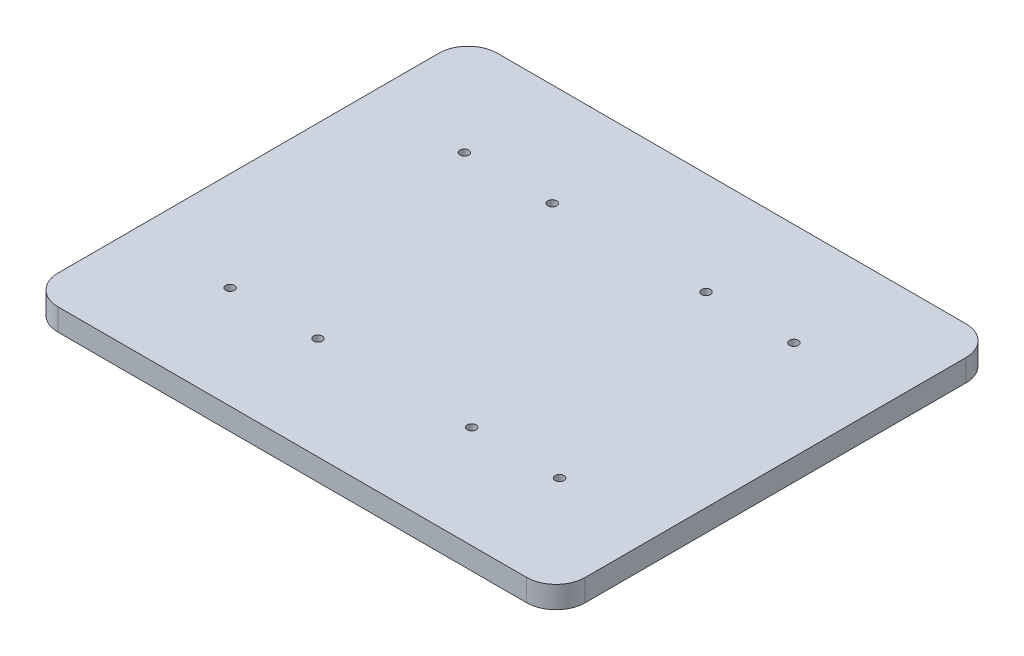
from build123d import *

# Parameters (mm, degrees)
SKETCH2_W                 = 360
SKETCH2_H                 = 300
BOSS_EXTRUDE1_DEPTH       = 15
FILLET1_R                 = 20
F_6_0MM_DOWEL_HOLE1_D     = 6
F_6_0MM_DOWEL_HOLE1_DEPTH = 15


with BuildPart() as part:
    # Sketch2 → Boss-Extrude1 (new body)
    with BuildSketch(Plane(origin=(0, 0, 0), x_dir=(1, 0, 0), z_dir=(0, 1, 0))):
        Rectangle(SKETCH2_W, SKETCH2_H)
    extrude(amount=BOSS_EXTRUDE1_DEPTH)

    # Fillet1
    fillet1_edges = [part.edges().sort_by_distance(p)[0] for p in [
        (180, 7.5, 150),
        (-180, 7.5, 150),
        (-180, 7.5, -150),
        (180, 7.5, -150),
    ]]
    fillet(fillet1_edges, radius=FILLET1_R)

    # Ø6.0mm Dowel Hole1
    with Locations(Plane(origin=(-112.5, 15, 80), x_dir=(0, 0, 1), z_dir=(0, 1, 0))):
        with Locations((0, 0), (0, 60), (0, 165), (0, 225), (-160, 225), (-160, 165), (-160, 60), (-160, 0)):
            Hole(F_6_0MM_DOWEL_HOLE1_D / 2, depth=F_6_0MM_DOWEL_HOLE1_DEPTH)


solid = part.part
